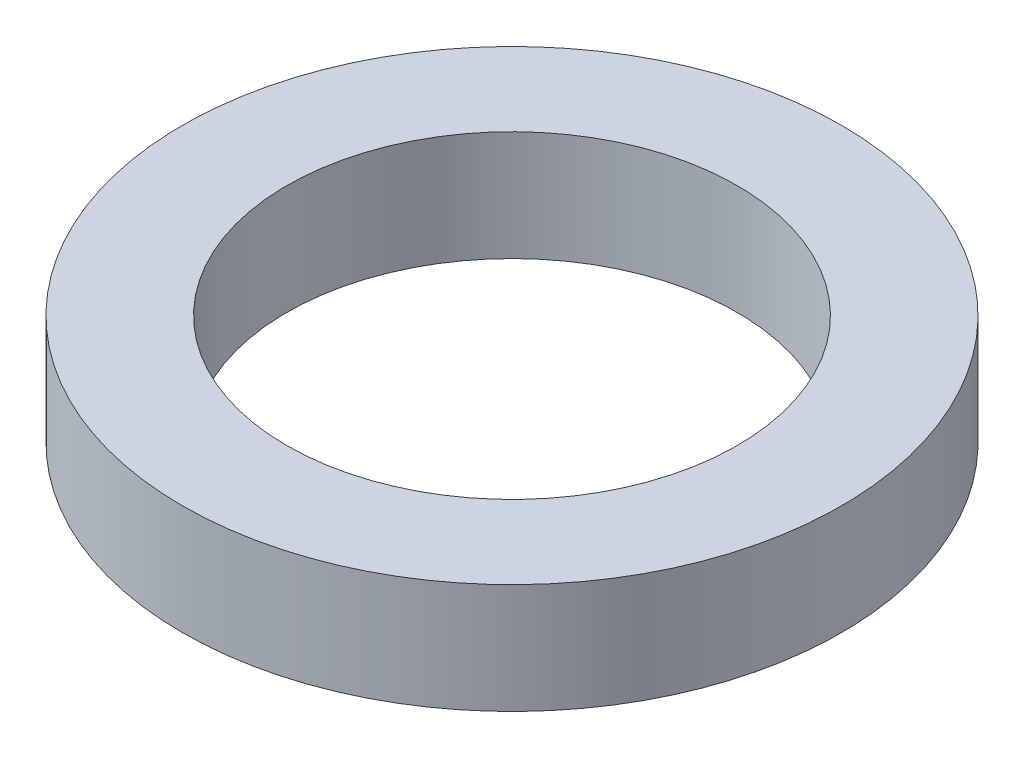
from build123d import *

# Parameters (mm, degrees)
SKETCH1_R           = 6
SKETCH1_R_2         = 4.1
BOSS_EXTRUDE1_DEPTH = 2


with BuildPart() as part:
    # Sketch1 → Boss-Extrude1 (new body)
    with BuildSketch(Plane(origin=(0, 0, 0), x_dir=(1, 0, 0), z_dir=(0, 1, 0))):
        Circle(SKETCH1_R)
        Circle(SKETCH1_R_2, mode=Mode.SUBTRACT)
    extrude(amount=BOSS_EXTRUDE1_DEPTH)


solid = part.part
